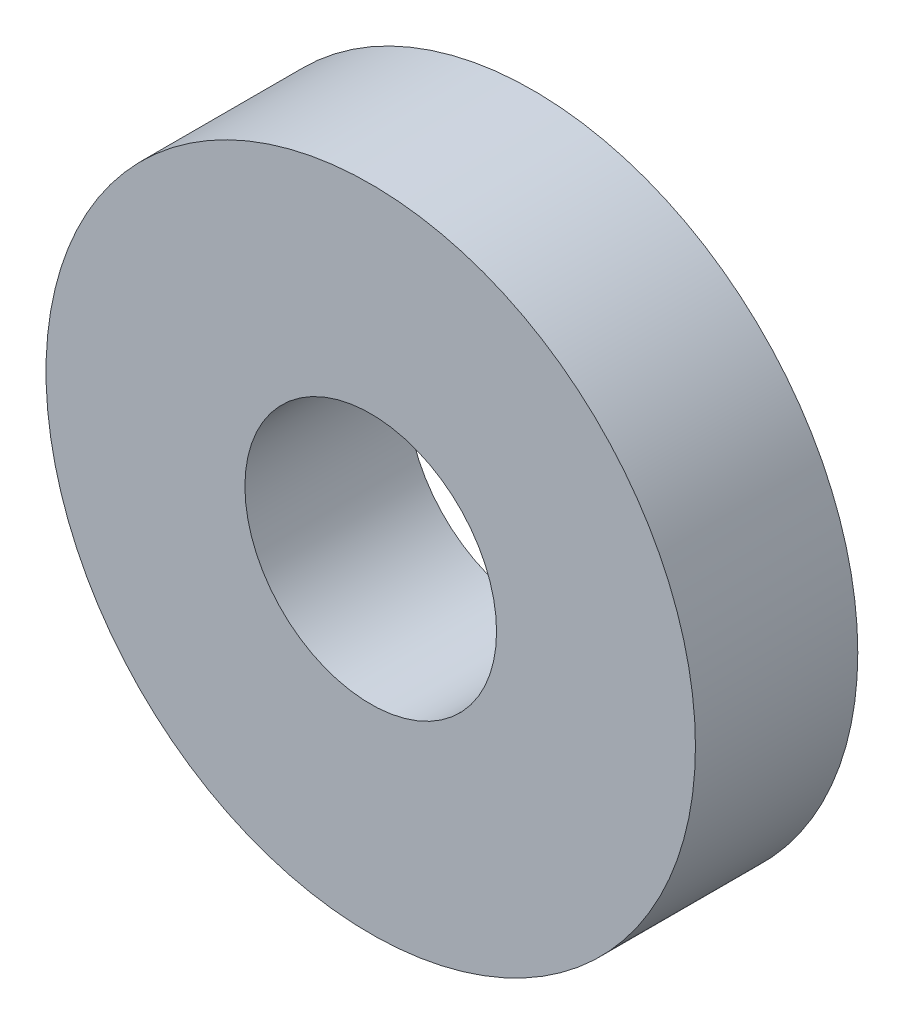
from build123d import *

# Parameters (mm, degrees)
SKETCH1_R              = 4
BOSS_EXTRUDE1_DEPTH    = 2
M2_5_CLEARANCE_HOLE1_D = 3.1


with BuildPart() as part:
    # Sketch1 → Boss-Extrude1 (new body)
    with BuildSketch(Plane.XY):
        Circle(SKETCH1_R)
    extrude(amount=BOSS_EXTRUDE1_DEPTH)

    # M2.5 Clearance Hole1 (through all)
    with Locations(Plane.XY.offset(2)):
        with Locations((0, 0)):
            Hole(M2_5_CLEARANCE_HOLE1_D / 2)


solid = part.part
